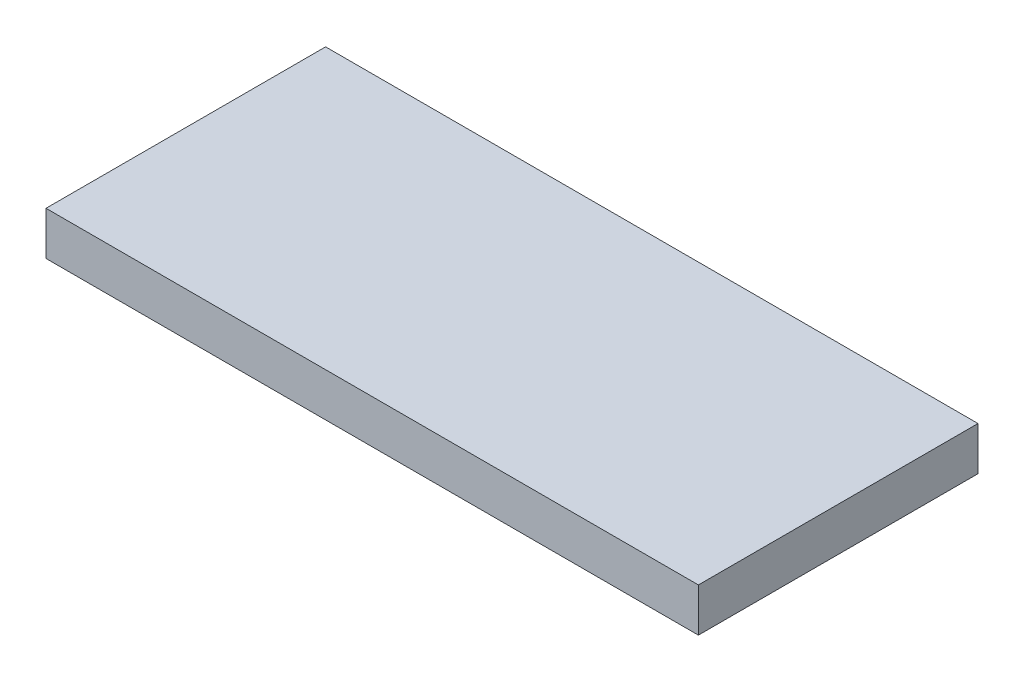
from build123d import *

# Parameters (mm, degrees)
ESQUISSE1_W        = 150
ESQUISSE1_H        = 64.285714286
BOSS_EXTRU_1_DEPTH = 10


with BuildPart() as part:
    # Esquisse1 → Boss.-Extru.1 (new body)
    with BuildSketch(Plane(origin=(0, 0, 0), x_dir=(1, 0, 0), z_dir=(0, 1, 0))):
        with Locations((75, 32.142857143)):
            Rectangle(ESQUISSE1_W, ESQUISSE1_H)
    extrude(amount=BOSS_EXTRU_1_DEPTH)


solid = part.part
